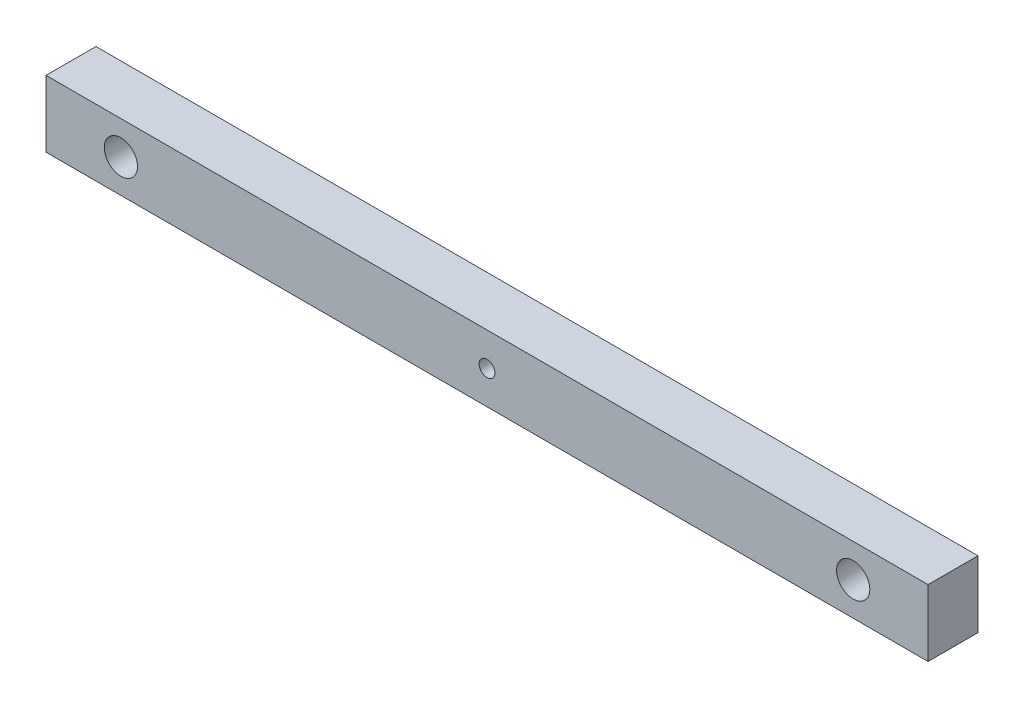
from build123d import *

# Parameters (mm, degrees)
SKETCH1_W           = 53
SKETCH1_H           = 4
BOSS_EXTRUDE2_DEPTH = 3
SKETCH3_R           = 1
CUT_EXTRUDE2_DEPTH  = 3
SKETCH4_R           = 0.475
CUT_EXTRUDE3_DEPTH  = 3


with BuildPart() as part:
    # Sketch1 → Boss-Extrude2 (new body)
    with BuildSketch(Plane.XY):
        with Locations((-12.412207578, 0)):
            Rectangle(SKETCH1_W, SKETCH1_H)
    extrude(amount=BOSS_EXTRUDE2_DEPTH)

    # Sketch3 → Cut-Extrude2 (cut)
    with BuildSketch(Plane.XY.offset(3)):
        with Locations((-34.412207578, 0)):
            Circle(SKETCH3_R)
        with Locations((9.587792422, 0)):
            Circle(SKETCH3_R)
    extrude(amount=-CUT_EXTRUDE2_DEPTH, mode=Mode.SUBTRACT)

    # Sketch4 → Cut-Extrude3 (cut)
    with BuildSketch(Plane(origin=(0, 0, 0), x_dir=(-1, 0, 0), z_dir=(0, 0, -1))):
        with Locations((12.412207578, 0)):
            Circle(SKETCH4_R)
    extrude(amount=-CUT_EXTRUDE3_DEPTH, mode=Mode.SUBTRACT)


solid = part.part
